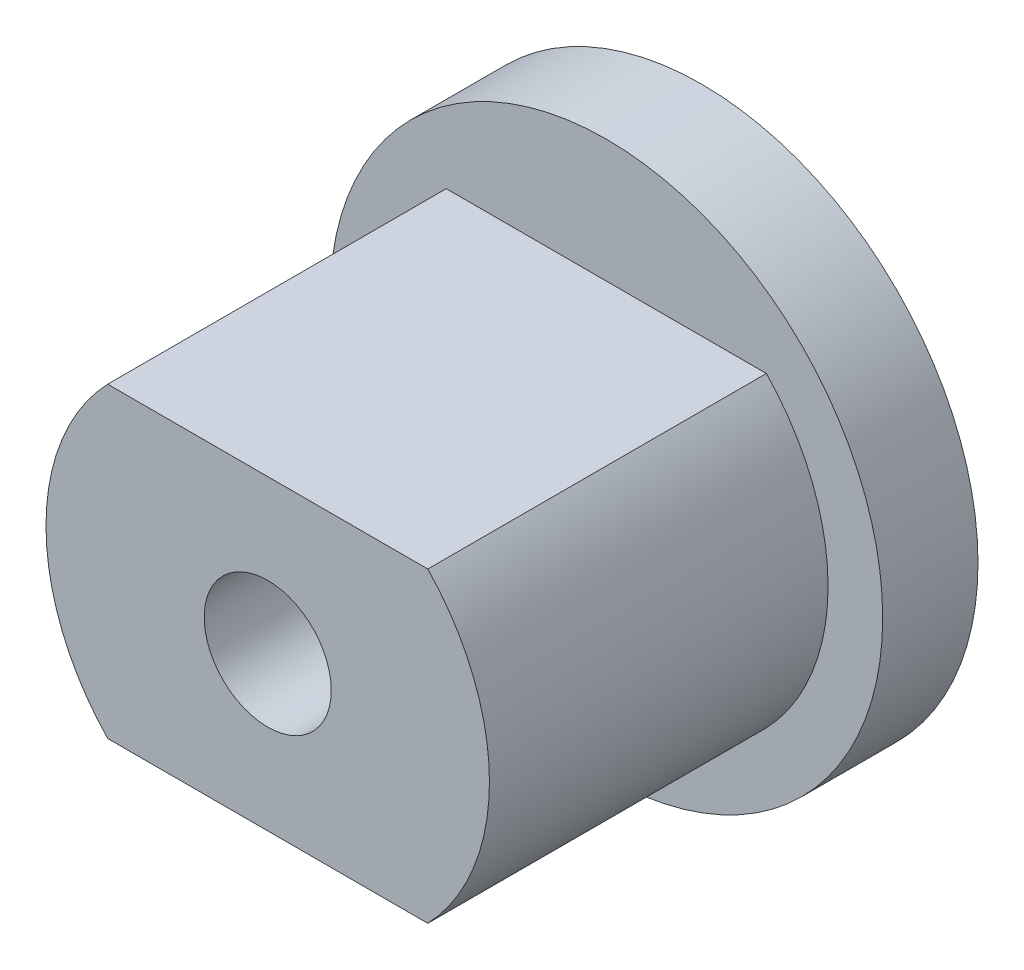
from build123d import *

# Parameters (mm, degrees)
BOSS_EXTRU_1_DEPTH      = 5.33
ESQUISSE2_R             = 1
ENL_V_MAT_EXTRU_1_DEPTH = 3
ESQUISSE3_R             = 4.35
BOSS_EXTRU_2_DEPTH      = 1.5


with BuildPart() as part:
    # Esquisse1 → Boss.-Extru.1 (new body)
    with BuildSketch(Plane.XY):
        with BuildLine():
            Line((-2.519498958, 2.415), (2.519498958, 2.415))
            ThreePointArc((2.519498958, 2.415), (3.49, 0), (2.519498958, -2.415))
            Line((2.519498958, -2.415), (-2.519498958, -2.415))
            ThreePointArc((-2.519498958, -2.415), (-3.49, 0), (-2.519498958, 2.415))
        make_face()
    extrude(amount=BOSS_EXTRU_1_DEPTH)

    # Esquisse2 → Enlèv. mat.-Extru.1 (cut)
    with BuildSketch(Plane.XY.offset(5.33)):
        Circle(ESQUISSE2_R)
    extrude(amount=-ENL_V_MAT_EXTRU_1_DEPTH, mode=Mode.SUBTRACT)

    # Esquisse3 → Boss.-Extru.2 (add)
    with BuildSketch(Plane(origin=(0, 0, 0), x_dir=(-1, 0, 0), z_dir=(0, 0, -1))):
        Circle(ESQUISSE3_R)
    extrude(amount=BOSS_EXTRU_2_DEPTH)


solid = part.part
